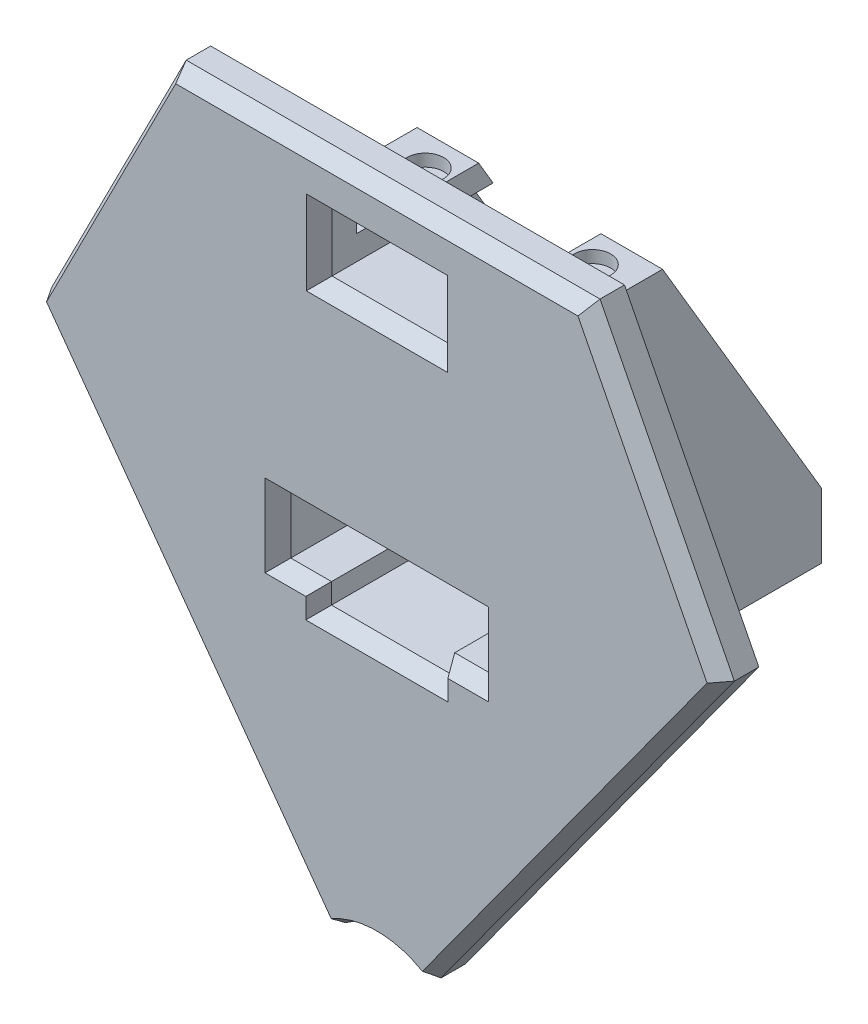
from build123d import *

# Parameters (mm, degrees)
BOSS_EXTRUDE1_DEPTH     = 32.5
SKETCH4_R               = 1.05
BOSS_EXTRUDE2_DEPTH     = 2.5
SKETCH5_R               = 1.05
BOSS_EXTRUDE3_DEPTH     = 3
CUT_EXTRUDE1_DEPTH      = 31.122
SKETCH13_W              = 30.122
SKETCH13_H              = 38
BOSS_EXTRUDE7_DEPTH     = 2.5
BOSS_EXTRUDE4_DEPTH     = 5
BOSS_EXTRUDE6_DEPTH     = 5
CUT_EXTRUDE2_DEPTH      = 6
SKETCH14_W              = 15
SKETCH14_H              = 5
CUT_EXTRUDE3_DEPTH      = 11
SKETCH15_W              = 30.122
SKETCH15_H              = 34.5
SKETCH15_R              = 2.495
BOSS_EXTRUDE8_DEPTH     = 3
SKETCH17_R              = 13.75
CUT_EXTRUDE4_DEPTH      = 53
SKETCH19_W              = 15
SKETCH19_H              = 3
CUT_EXTRUDE6_DEPTH      = 30.5
CUT_EXTRUDE6_DEPTH_BACK = 11
SKETCH21_R              = 2.25
CUT_EXTRUDE8_DEPTH      = 1.5
SKETCH20_R              = 10
CUT_EXTRUDE7_DEPTH      = 6
CHAMFER1_SIZE           = 2
CHAMFER1_SIZE2          = 1.154700538
CHAMFER1_PART_2_SIZE    = 2
CHAMFER1_PART_2_SIZE2   = 1.154700538
CHAMFER1_PART_3_SIZE    = 2
CHAMFER1_PART_3_SIZE2   = 1.154700538
CHAMFER1_PART_4_SIZE    = 2
CHAMFER1_PART_4_SIZE2   = 1.154700538
CHAMFER1_PART_5_SIZE    = 2
CHAMFER1_PART_5_SIZE2   = 1.154700538
CHAMFER1_PART_6_SIZE    = 2
CHAMFER1_PART_6_SIZE2   = 1.154700538
CHAMFER1_PART_7_SIZE    = 2
CHAMFER1_PART_7_SIZE2   = 1.154700538
CHAMFER1_PART_8_SIZE    = 2
CHAMFER1_PART_8_SIZE2   = 1.154700538
CHAMFER1_PART_9_SIZE    = 2
CHAMFER1_PART_9_SIZE2   = 1.154700538
CHAMFER1_PART_10_SIZE   = 2
CHAMFER1_PART_10_SIZE2  = 1.154700538
CHAMFER1_PART_11_SIZE   = 2
CHAMFER1_PART_11_SIZE2  = 1.154700538
CHAMFER1_PART_12_SIZE   = 2
CHAMFER1_PART_12_SIZE2  = 1.154700538
CHAMFER1_PART_13_SIZE   = 2
CHAMFER1_PART_13_SIZE2  = 1.154700538
CHAMFER1_PART_14_SIZE   = 2
CHAMFER1_PART_14_SIZE2  = 1.154700538
CHAMFER1_PART_15_SIZE   = 2
CHAMFER1_PART_15_SIZE2  = 1.154700538
CHAMFER1_PART_16_SIZE   = 2
CHAMFER1_PART_16_SIZE2  = 1.154700538
CHAMFER1_PART_17_SIZE   = 2
CHAMFER1_PART_17_SIZE2  = 1.154700538
CHAMFER1_PART_18_SIZE   = 2
CHAMFER1_PART_18_SIZE2  = 1.154700538


with BuildPart() as part:
    # Sketch2 → Boss-Extrude1 (new body)
    with BuildSketch(Plane(origin=(0, 0, 0), x_dir=(1, 0, 0), z_dir=(0, 1, 0))):
        Polygon((15.061, 0), (15.061, 32), (12.561, 32), (12.561, 2.5), (-12.561, 2.5), (-12.561, 32), (-15.061, 32), (-15.061, 0), align=None)
    extrude(amount=BOSS_EXTRUDE1_DEPTH)

    # Sketch4 → Boss-Extrude2 (add)
    with BuildSketch(Plane.XZ):
        Polygon((-7.561, -6), (-7.561, 0), (-15.061, 0), (-15.061, -32), (-12.561, -32), (-12.561, -10), align=None)
        with Locations((-10.2499, -4.95)):
            Circle(SKETCH4_R, mode=Mode.SUBTRACT)
        Polygon((12.561, -10), (7.561, -6), (7.561, 0), (15.061, 0), (15.061, -32), (12.561, -32), align=None)
        with Locations((10.2499, -4.95)):
            Circle(SKETCH4_R, mode=Mode.SUBTRACT)
    extrude(amount=BOSS_EXTRUDE2_DEPTH)

    # Sketch5 → Boss-Extrude3 (add)
    with BuildSketch(Plane(origin=(0, 32.5, 0), x_dir=(1, 0, 0), z_dir=(0, 1, 0))):
        Polygon((-15.061, 32), (-10.2499, 32), (-6.25, 26), (6.25, 26), (10.2499, 32), (15.061, 32), (15.061, 0), (-15.061, 0), align=None)
        with Locations((-10.2499, 8.7)):
            Circle(SKETCH5_R, mode=Mode.SUBTRACT)
        with Locations((10.2499, 8.7)):
            Circle(SKETCH5_R, mode=Mode.SUBTRACT)
    extrude(amount=BOSS_EXTRUDE3_DEPTH)

    # Sketch6 → Cut-Extrude1 (cut, through all)
    with BuildSketch(Plane.ZY.offset(15.061)):
        Polygon((-12.5, 35.5), (-32, 2.5), (-32, 35.5), align=None)
    extrude(amount=-CUT_EXTRUDE1_DEPTH, mode=Mode.SUBTRACT)

    # Sketch13 → Boss-Extrude7 (add)
    with BuildSketch(Plane.XY):
        with Locations((0, 16.5)):
            Rectangle(SKETCH13_W, SKETCH13_H)
    extrude(amount=BOSS_EXTRUDE7_DEPTH)

    # Sketch8 → Boss-Extrude4 (add)
    with BuildSketch(Plane.XY.offset(2.5)):
        Polygon((0, -43.5), (-43.59255168, 16.5), (43.59255168, 16.5), align=None)
    extrude(amount=BOSS_EXTRUDE4_DEPTH)

    # Sketch9 → Boss-Extrude6 (add)
    with BuildSketch(Plane.XY.offset(2.5)):
        Polygon((43.59255168, 16.5), (65.38882752, 46.5), (-65.38882752, 46.5), (-43.59255168, 16.5), align=None)
    extrude(amount=BOSS_EXTRUDE6_DEPTH)

    # Sketch10 → Cut-Extrude2 (cut, through all)
    with BuildSketch(Plane(origin=(0, 0, 2.5), x_dir=(-1, 0, 0), z_dir=(0, 0, -1))):
        Polygon((-25.38882752, 46.5), (-65.38882752, 46.5), (-41.877417429, 14.139320225), align=None)
        Polygon((65.38882752, 46.5), (41.877417429, 14.139320225), (25.38882752, 46.5), align=None)
    extrude(amount=-CUT_EXTRUDE2_DEPTH, mode=Mode.SUBTRACT)

    # Sketch14 → Cut-Extrude3 (cut, through all)
    with BuildSketch(Plane(origin=(0, 0, -2.5), x_dir=(-1, 0, 0), z_dir=(0, 0, -1))):
        Polygon((-7.561, -2.5), (7.561, -2.5), (7.561, 0), (12.561, 0), (12.561, 7.783674653), (-12.561, 7.783674653), (-12.561, 0), (-7.561, 0), align=None)
        with Locations((0, 38)):
            Rectangle(SKETCH14_W, SKETCH14_H)
    extrude(amount=-CUT_EXTRUDE3_DEPTH, mode=Mode.SUBTRACT)

    # Sketch15 → Boss-Extrude8 (add)
    with BuildSketch(Plane.XZ.offset(2.5)):
        with Locations((0, -14.75)):
            Rectangle(SKETCH15_W, SKETCH15_H)
        with Locations((-10.2499, -4.95)):
            Circle(SKETCH15_R, mode=Mode.SUBTRACT)
        with Locations((10.340989886, -4.95)):
            Circle(SKETCH15_R, mode=Mode.SUBTRACT)
    extrude(amount=BOSS_EXTRUDE8_DEPTH)

    # Sketch17 → Cut-Extrude4 (cut, through all)
    with BuildSketch(Plane.XZ.offset(5.5)):
        with Locations((0, -37.5)):
            Circle(SKETCH17_R)
    extrude(amount=-CUT_EXTRUDE4_DEPTH, mode=Mode.SUBTRACT)

    # Sketch19 → Cut-Extrude6 (cut, two sides)
    with BuildSketch(Plane(origin=(0, 0, -2.5), x_dir=(-1, 0, 0), z_dir=(0, 0, -1))) as cut_extrude6_sk:
        with Locations((0, 34)):
            Rectangle(SKETCH19_W, SKETCH19_H)
    extrude(amount=CUT_EXTRUDE6_DEPTH, mode=Mode.SUBTRACT)
    extrude(cut_extrude6_sk.sketch, amount=-CUT_EXTRUDE6_DEPTH_BACK, mode=Mode.SUBTRACT)

    # Sketch21 → Cut-Extrude8 (cut)
    with BuildSketch(Plane(origin=(0, 35.5, 0), x_dir=(1, 0, 0), z_dir=(0, 1, 0))):
        with Locations((-10.2499, 8.7)):
            Circle(SKETCH21_R)
        with Locations((10.2499, 8.7)):
            Circle(SKETCH21_R)
    extrude(amount=-CUT_EXTRUDE8_DEPTH, mode=Mode.SUBTRACT)

    # Sketch20 → Cut-Extrude7 (cut, through all)
    with BuildSketch(Plane(origin=(0, 0, 2.5), x_dir=(-1, 0, 0), z_dir=(0, 0, -1))):
        with Locations((0, -43.5)):
            Circle(SKETCH20_R)
    extrude(amount=-CUT_EXTRUDE7_DEPTH, mode=Mode.SUBTRACT)

    # Chamfer1
    chamfer1_edges = [part.edges().sort_by_distance(p)[0] for p in [
        (-23.877634976, -10.635254916, 7.5),
    ]]
    chamfer1_side = [part.faces().sort_by_distance(p)[0] for p in [
        (-23.877634976, -10.635254916, 5),
    ]]
    chamfer(chamfer1_edges, length=CHAMFER1_SIZE, length2=CHAMFER1_SIZE2, reference=chamfer1_side[0])

    # Chamfer1 part 2
    chamfer1_part_2_edges = [part.edges().sort_by_distance(p)[0] for p in [
        (-33.633122475, 30.319660113, 7.5),
    ]]
    chamfer1_part_2_side = [part.faces().sort_by_distance(p)[0] for p in [
        (-33.633122475, 30.319660113, 5),
    ]]
    chamfer(chamfer1_part_2_edges, length=CHAMFER1_PART_2_SIZE, length2=CHAMFER1_PART_2_SIZE2, reference=chamfer1_part_2_side[0])

    # Chamfer1 part 3
    chamfer1_part_3_edges = [part.edges().sort_by_distance(p)[0] for p in [
        (0, 46.5, 7.5),
    ]]
    chamfer1_part_3_side = [part.faces().sort_by_distance(p)[0] for p in [
        (0, 46.5, 5),
    ]]
    chamfer(chamfer1_part_3_edges, length=CHAMFER1_PART_3_SIZE, length2=CHAMFER1_PART_3_SIZE2, reference=chamfer1_part_3_side[0])

    # Chamfer1 part 4
    chamfer1_part_4_edges = [part.edges().sort_by_distance(p)[0] for p in [
        (33.633122475, 30.319660113, 7.5),
    ]]
    chamfer1_part_4_side = [part.faces().sort_by_distance(p)[0] for p in [
        (33.633122475, 30.319660113, 5),
    ]]
    chamfer(chamfer1_part_4_edges, length=CHAMFER1_PART_4_SIZE, length2=CHAMFER1_PART_4_SIZE2, reference=chamfer1_part_4_side[0])

    # Chamfer1 part 5
    chamfer1_part_5_edges = [part.edges().sort_by_distance(p)[0] for p in [
        (23.877634976, -10.635254916, 7.5),
    ]]
    chamfer1_part_5_side = [part.faces().sort_by_distance(p)[0] for p in [
        (23.877634976, -10.635254916, 5),
    ]]
    chamfer(chamfer1_part_5_edges, length=CHAMFER1_PART_5_SIZE, length2=CHAMFER1_PART_5_SIZE2, reference=chamfer1_part_5_side[0])

    # Chamfer1 part 6
    chamfer1_part_6_edges = [part.edges().sort_by_distance(p)[0] for p in [
        (0, -33.5, 7.5),
    ]]
    chamfer1_part_6_side = [part.faces().sort_by_distance(p)[0] for p in [
        (0, -33.5, 5),
    ]]
    chamfer(chamfer1_part_6_edges, length=CHAMFER1_PART_6_SIZE, length2=CHAMFER1_PART_6_SIZE2, reference=chamfer1_part_6_side[0])

    # Chamfer1 part 7
    chamfer1_part_7_edges = [part.edges().sort_by_distance(p)[0] for p in [
        (7.5, 36.5, 7.5),
    ]]
    chamfer1_part_7_side = [part.faces().sort_by_distance(p)[0] for p in [
        (7.5, 35.125615764, -0.682301365),
    ]]
    chamfer(chamfer1_part_7_edges, length=CHAMFER1_PART_7_SIZE, length2=CHAMFER1_PART_7_SIZE2, reference=chamfer1_part_7_side[0])

    # Chamfer1 part 8
    chamfer1_part_8_edges = [part.edges().sort_by_distance(p)[0] for p in [
        (0, 40.5, 7.5),
    ]]
    chamfer1_part_8_side = [part.faces().sort_by_distance(p)[0] for p in [
        (0, 40.5, 5),
    ]]
    chamfer(chamfer1_part_8_edges, length=CHAMFER1_PART_8_SIZE, length2=CHAMFER1_PART_8_SIZE2, reference=chamfer1_part_8_side[0])

    # Chamfer1 part 9
    chamfer1_part_9_edges = [part.edges().sort_by_distance(p)[0] for p in [
        (-7.5, 36.5, 7.5),
    ]]
    chamfer1_part_9_side = [part.faces().sort_by_distance(p)[0] for p in [
        (-7.5, 35.125615764, -0.682301365),
    ]]
    chamfer(chamfer1_part_9_edges, length=CHAMFER1_PART_9_SIZE, length2=CHAMFER1_PART_9_SIZE2, reference=chamfer1_part_9_side[0])

    # Chamfer1 part 10
    chamfer1_part_10_edges = [part.edges().sort_by_distance(p)[0] for p in [
        (12.561, 3.891837327, 7.5),
    ]]
    chamfer1_part_10_side = [part.faces().sort_by_distance(p)[0] for p in [
        (12.561, 11.913281954, -12.779758376),
    ]]
    chamfer(chamfer1_part_10_edges, length=CHAMFER1_PART_10_SIZE, length2=CHAMFER1_PART_10_SIZE2, reference=chamfer1_part_10_side[0])

    # Chamfer1 part 11
    chamfer1_part_11_edges = [part.edges().sort_by_distance(p)[0] for p in [
        (0, -2.5, 7.5),
    ]]
    chamfer1_part_11_side = [part.faces().sort_by_distance(p)[0] for p in [
        (0, -2.5, -11.382409491),
    ]]
    chamfer(chamfer1_part_11_edges, length=CHAMFER1_PART_11_SIZE, length2=CHAMFER1_PART_11_SIZE2, reference=chamfer1_part_11_side[0])

    # Chamfer1 part 12
    chamfer1_part_12_edges = [part.edges().sort_by_distance(p)[0] for p in [
        (-7.561, -1.25, 7.5),
    ]]
    chamfer1_part_12_side = [part.faces().sort_by_distance(p)[0] for p in [
        (-7.561, -1.25, 0.75),
    ]]
    chamfer(chamfer1_part_12_edges, length=CHAMFER1_PART_12_SIZE, length2=CHAMFER1_PART_12_SIZE2, reference=chamfer1_part_12_side[0])

    # Chamfer1 part 13
    chamfer1_part_13_edges = [part.edges().sort_by_distance(p)[0] for p in [
        (7.561, -1.25, 7.5),
    ]]
    chamfer1_part_13_side = [part.faces().sort_by_distance(p)[0] for p in [
        (7.561, -1.25, 0.75),
    ]]
    chamfer(chamfer1_part_13_edges, length=CHAMFER1_PART_13_SIZE, length2=CHAMFER1_PART_13_SIZE2, reference=chamfer1_part_13_side[0])

    # Chamfer1 part 14
    chamfer1_part_14_edges = [part.edges().sort_by_distance(p)[0] for p in [
        (-10.061, 0, 7.5),
    ]]
    chamfer1_part_14_side = [part.faces().sort_by_distance(p)[0] for p in [
        (-10.164720046, 0, -0.075145261),
    ]]
    chamfer(chamfer1_part_14_edges, length=CHAMFER1_PART_14_SIZE, length2=CHAMFER1_PART_14_SIZE2, reference=chamfer1_part_14_side[0])

    # Chamfer1 part 15
    chamfer1_part_15_edges = [part.edges().sort_by_distance(p)[0] for p in [
        (10.061, 0, 7.5),
    ]]
    chamfer1_part_15_side = [part.faces().sort_by_distance(p)[0] for p in [
        (10.164720046, 0, -0.075145261),
    ]]
    chamfer(chamfer1_part_15_edges, length=CHAMFER1_PART_15_SIZE, length2=CHAMFER1_PART_15_SIZE2, reference=chamfer1_part_15_side[0])

    # Chamfer1 part 16
    chamfer1_part_16_edges = [part.edges().sort_by_distance(p)[0] for p in [
        (-12.561, 3.891837327, 7.5),
    ]]
    chamfer1_part_16_side = [part.faces().sort_by_distance(p)[0] for p in [
        (-12.561, 11.913281954, -12.779758376),
    ]]
    chamfer(chamfer1_part_16_edges, length=CHAMFER1_PART_16_SIZE, length2=CHAMFER1_PART_16_SIZE2, reference=chamfer1_part_16_side[0])

    # Chamfer1 part 17
    chamfer1_part_17_edges = [part.edges().sort_by_distance(p)[0] for p in [
        (0, 7.783674653, 7.5),
    ]]
    chamfer1_part_17_side = [part.faces().sort_by_distance(p)[0] for p in [
        (0, 7.783674653, 2.5),
    ]]
    chamfer(chamfer1_part_17_edges, length=CHAMFER1_PART_17_SIZE, length2=CHAMFER1_PART_17_SIZE2, reference=chamfer1_part_17_side[0])

    # Chamfer1 part 18
    chamfer1_part_18_edges = [part.edges().sort_by_distance(p)[0] for p in [
        (0, 32.5, 7.5),
    ]]
    chamfer1_part_18_side = [part.faces().sort_by_distance(p)[0] for p in [
        (0, 32.5, 2.5),
    ]]
    chamfer(chamfer1_part_18_edges, length=CHAMFER1_PART_18_SIZE, length2=CHAMFER1_PART_18_SIZE2, reference=chamfer1_part_18_side[0])


solid = part.part
